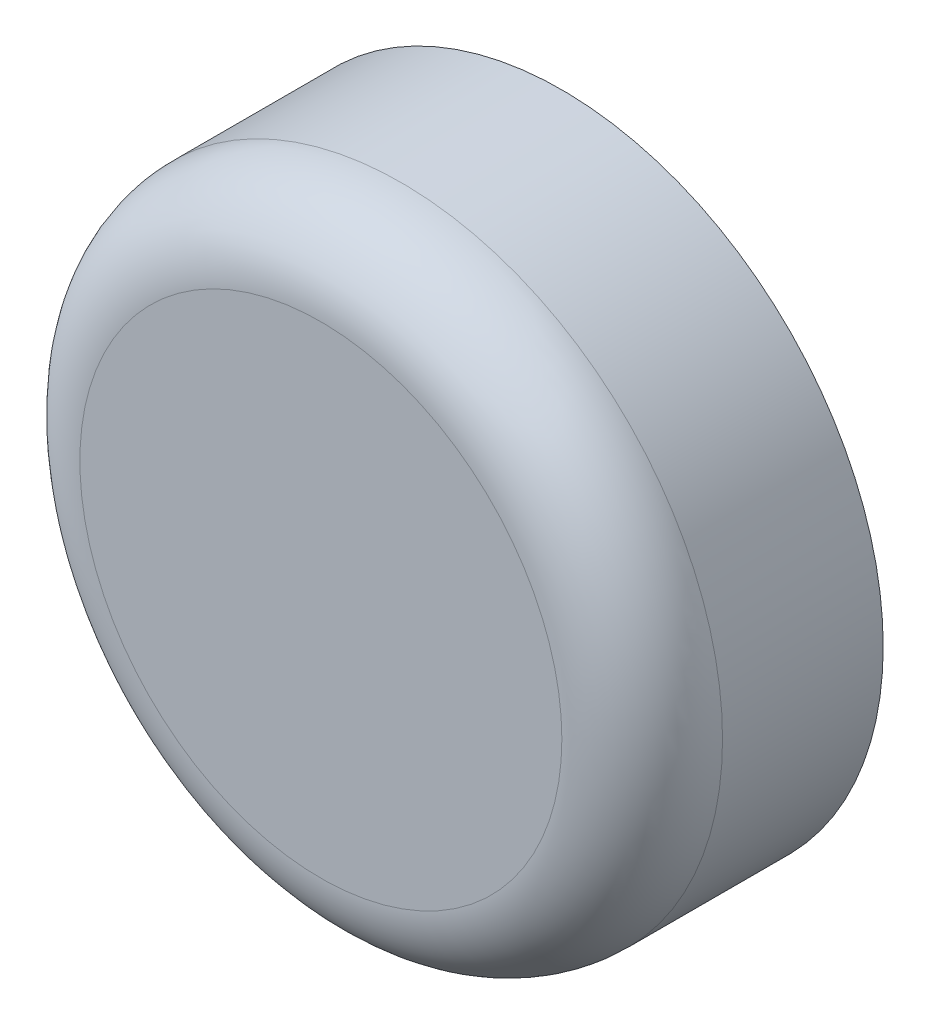
from build123d import *

# Parameters (mm, degrees)
SKIZZE1_R                       = 20
AUFSATZ_LINEAR_AUSTRAGEN1_DEPTH = 15
VERRUNDUNG1_R                   = 5
SKIZZE2_W                       = 10
SKIZZE2_H                       = 25
SCHNITT_LINEAR_AUSTRAGEN1_DEPTH = 10
SKIZZE3_R                       = 1.25
SCHNITT_LINEAR_AUSTRAGEN2_DEPTH = 5


with BuildPart() as part:
    # Skizze1 → Aufsatz-Linear austragen1 (new body)
    with BuildSketch(Plane.XY):
        Circle(SKIZZE1_R)
    extrude(amount=AUFSATZ_LINEAR_AUSTRAGEN1_DEPTH)

    # Verrundung1
    verrundung1_edges = [part.edges().sort_by_distance(p)[0] for p in [
        (-20, 0, 15),
    ]]
    fillet(verrundung1_edges, radius=VERRUNDUNG1_R)

    # Skizze2 → Schnitt-Linear austragen1 (cut)
    with BuildSketch(Plane(origin=(0, 0, 0), x_dir=(-1, 0, 0), z_dir=(0, 0, -1))):
        Rectangle(SKIZZE2_W, SKIZZE2_H)
    extrude(amount=-SCHNITT_LINEAR_AUSTRAGEN1_DEPTH, mode=Mode.SUBTRACT)

    # Skizze3 → Schnitt-Linear austragen2 (cut)
    with BuildSketch(Plane(origin=(0, 0, 0), x_dir=(-1, 0, 0), z_dir=(0, 0, -1))):
        with Locations((-13, 0)):
            Circle(SKIZZE3_R)
        with Locations((13, 0)):
            Circle(SKIZZE3_R)
    extrude(amount=-SCHNITT_LINEAR_AUSTRAGEN2_DEPTH, mode=Mode.SUBTRACT)


solid = part.part
